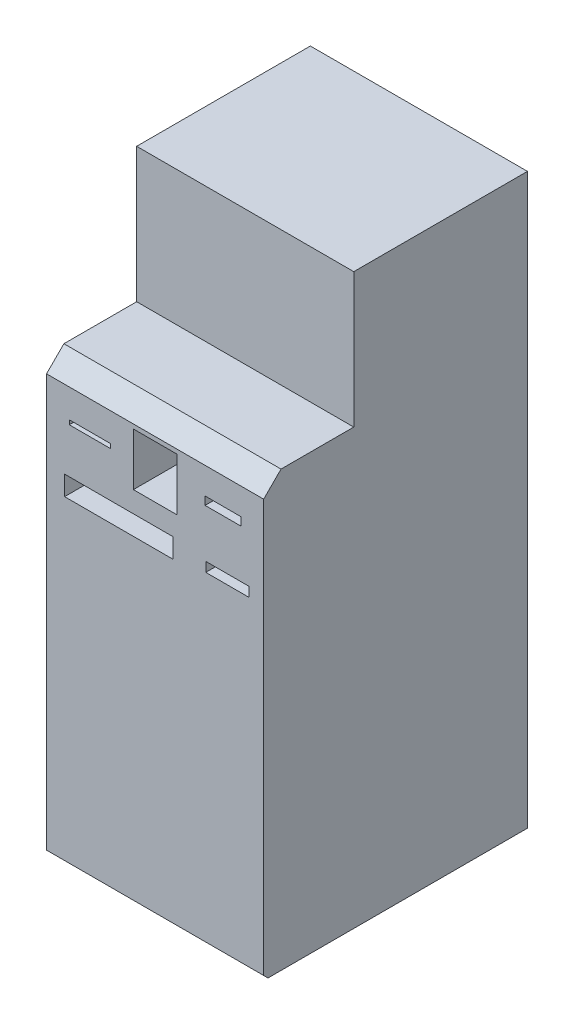
from build123d import *

# Parameters (mm, degrees)
BOSS_EXTRUDE1_DEPTH = 500
SKETCH2_W           = 100
SKETCH2_H           = 121
SKETCH2_W_2         = 95.3
SKETCH2_H_2         = 10
SKETCH2_W_3         = 82.54
SKETCH2_H_3         = 18.8
SKETCH2_H_4         = 22
SKETCH2_W_4         = 250
SKETCH2_H_5         = 45
CUT_EXTRUDE1_DEPTH  = 268


with BuildPart() as part:
    # Sketch1 → Boss-Extrude1 (new body)
    with BuildSketch(Plane(origin=(0, 0, 0), x_dir=(0, 0, -1), z_dir=(1, 0, 0))):
        Polygon((0, 0), (-190, 0), (-200, 10), (-200, 960), (-160, 1000), (7.526077778, 1000), (7.526077778, 1310), (57.526077778, 1310), (407.526077778, 1310), (407.526077778, 1000), (407.526077778, 970), (407.526077778, 820), (407.526077778, 0), align=None)
    extrude(amount=BOSS_EXTRUDE1_DEPTH)

    # Sketch2 → Cut-Extrude1 (cut)
    with BuildSketch(Plane.XY.offset(200)):
        with Locations((250, 889.5)):
            Rectangle(SKETCH2_W, SKETCH2_H)
        with Locations((100, 889.5)):
            Rectangle(SKETCH2_W_2, SKETCH2_H_2)
        with Locations((406.38, 889.5)):
            Rectangle(SKETCH2_W_3, SKETCH2_H_3)
        with Locations((416.666666667, 758.294000626)):
            Rectangle(SKETCH2_W, SKETCH2_H_4)
        with Locations((166.666666667, 758.294000626)):
            Rectangle(SKETCH2_W_4, SKETCH2_H_5)
    extrude(amount=-CUT_EXTRUDE1_DEPTH, mode=Mode.SUBTRACT)


solid = part.part
